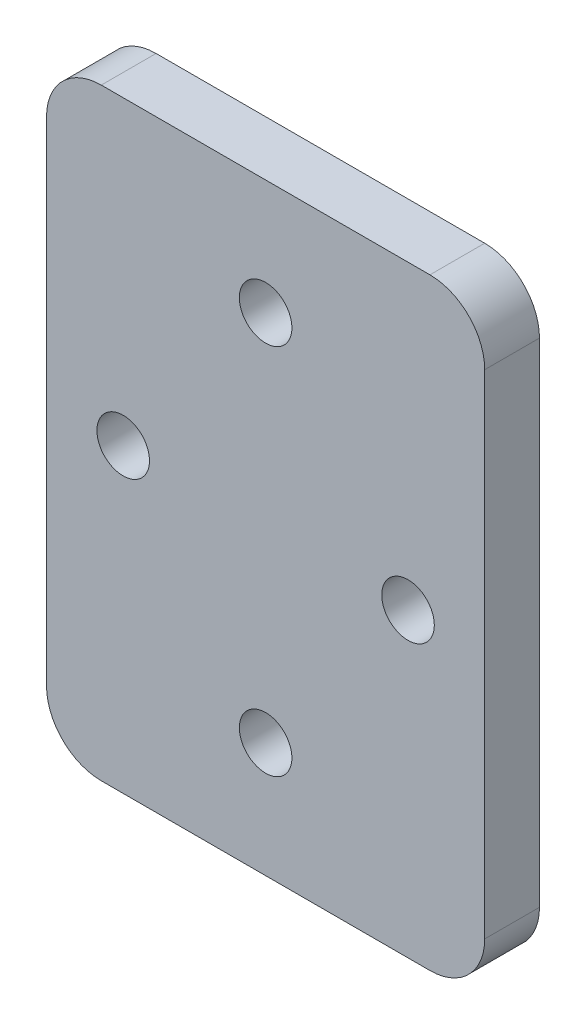
from build123d import *

# Parameters (mm, degrees)
SKETCH1_W           = 40
SKETCH1_H           = 55
SKETCH1_R           = 2.4
BOSS_EXTRUDE1_DEPTH = 5
FILLET1_R           = 5


with BuildPart() as part:
    # Sketch1 → Boss-Extrude1 (new body)
    with BuildSketch(Plane.XY):
        Rectangle(SKETCH1_W, SKETCH1_H)
        with Locations((0, 17)):
            Circle(SKETCH1_R, mode=Mode.SUBTRACT)
        with Locations((13, 0)):
            Circle(SKETCH1_R, mode=Mode.SUBTRACT)
        with Locations((0, -17)):
            Circle(SKETCH1_R, mode=Mode.SUBTRACT)
        with Locations((-13, 0)):
            Circle(SKETCH1_R, mode=Mode.SUBTRACT)
    extrude(amount=BOSS_EXTRUDE1_DEPTH)

    # Fillet1
    fillet1_edges = [part.edges().sort_by_distance(p)[0] for p in [
        (20, -27.5, 2.5),
        (-20, -27.5, 2.5),
        (-20, 27.5, 2.5),
        (20, 27.5, 2.5),
    ]]
    fillet(fillet1_edges, radius=FILLET1_R)


solid = part.part
